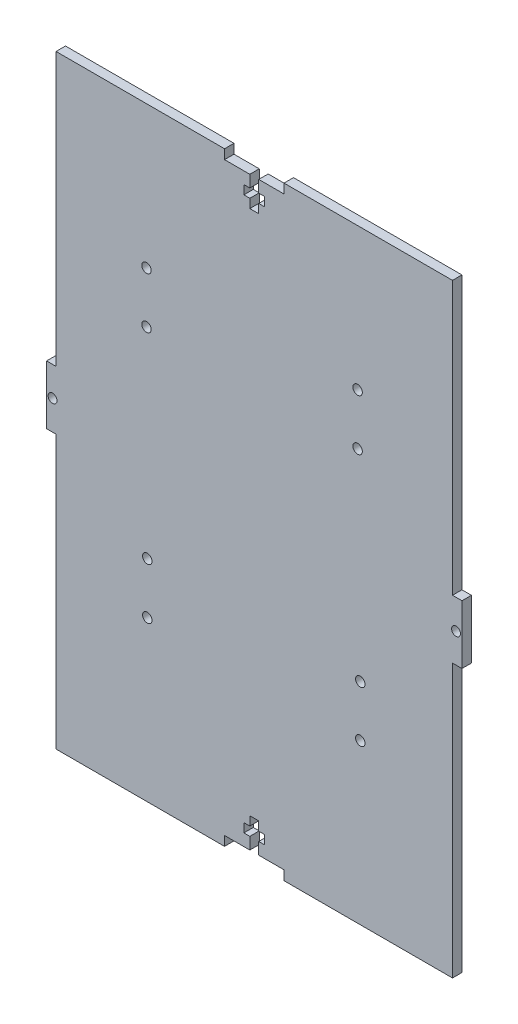
from build123d import *

# Parameters (mm, degrees)
SKETCH1_W           = 139.7
SKETCH1_H           = 203.2
BOSS_EXTRUDE1_DEPTH = 3.18
SKETCH2_R           = 1.5
SKETCH2_W           = 3.18
SKETCH2_H           = 91.725
CUT_EXTRUDE1_DEPTH  = 4.18
SKETCH3_R           = 1.59
CUT_EXTRUDE2_DEPTH  = 4.18
SKETCH4_R           = 1.59
CUT_EXTRUDE3_DEPTH  = 4.18


with BuildPart() as part:
    # Sketch1 → Boss-Extrude1 (new body)
    with BuildSketch(Plane.XY):
        Rectangle(SKETCH1_W, SKETCH1_H)
    extrude(amount=BOSS_EXTRUDE1_DEPTH)

    # Sketch2 → Cut-Extrude1 (cut, through all)
    with BuildSketch(Plane.XY.offset(3.18)):
        with Locations((-67.85, 0)):
            Circle(SKETCH2_R)
        with Locations((67.85, 0)):
            Circle(SKETCH2_R)
        Polygon((-10, 101.6), (10, 101.6), (10, 98.42), (1.5, 98.42), (1.5, 94.42), (3.5, 94.42), (3.5, 91.42), (1.5, 91.42), (1.5, 88.42), (-1.5, 88.42), (-1.5, 91.42), (-3.5, 91.42), (-3.5, 94.42), (-1.5, 94.42), (-1.5, 98.42), (-10, 98.42), align=None)
        Polygon((-10, -101.6), (-10, -98.42), (-1.5, -98.42), (-1.5, -94.42), (-3.5, -94.42), (-3.5, -91.42), (-1.5, -91.42), (-1.5, -88.42), (1.5, -88.42), (1.5, -91.42), (3.5, -91.42), (3.5, -94.42), (1.5, -94.42), (1.5, -98.42), (10, -98.42), (10, -101.6), align=None)
        with Locations((-68.26, 55.7375)):
            Rectangle(SKETCH2_W, SKETCH2_H)
        with Locations((-68.26, -55.7375)):
            Rectangle(SKETCH2_W, SKETCH2_H)
        with Locations((68.26, -55.7375)):
            Rectangle(SKETCH2_W, SKETCH2_H)
        with Locations((68.26, 55.7375)):
            Rectangle(SKETCH2_W, SKETCH2_H)
    extrude(amount=-CUT_EXTRUDE1_DEPTH, mode=Mode.SUBTRACT)

    # Sketch3 → Cut-Extrude2 (cut, through all)
    with BuildSketch(Plane(origin=(0, 0, 0), x_dir=(-1, 0, 0), z_dir=(0, 0, -1))):
        with Locations((-35.67127699, -47.963396943)):
            Circle(SKETCH3_R)
        with Locations((-35.67127699, -30.777287406)):
            Circle(SKETCH3_R)
    extrude(amount=-CUT_EXTRUDE2_DEPTH, mode=Mode.SUBTRACT)

    # Sketch4 → Cut-Extrude3 (cut, through all)
    with BuildSketch(Plane(origin=(0, 0, 0), x_dir=(-1, 0, 0), z_dir=(0, 0, -1))):
        with Locations((-34.750723073, 53.780323187)):
            Circle(SKETCH4_R)
        with Locations((-34.750723073, 36.59421365)):
            Circle(SKETCH4_R)
        with Locations((36.249784221, 53.780323187)):
            Circle(SKETCH4_R)
        with Locations((36.249784221, 36.59421365)):
            Circle(SKETCH4_R)
        with Locations((35.983928162, -30.777287406)):
            Circle(SKETCH4_R)
        with Locations((35.983928162, -47.963396943)):
            Circle(SKETCH4_R)
        with Locations((-35.67127699, -30.777287406)):
            Circle(SKETCH4_R)
        with Locations((-35.67127699, -47.963396943)):
            Circle(SKETCH4_R)
    extrude(amount=-CUT_EXTRUDE3_DEPTH, mode=Mode.SUBTRACT)


solid = part.part
